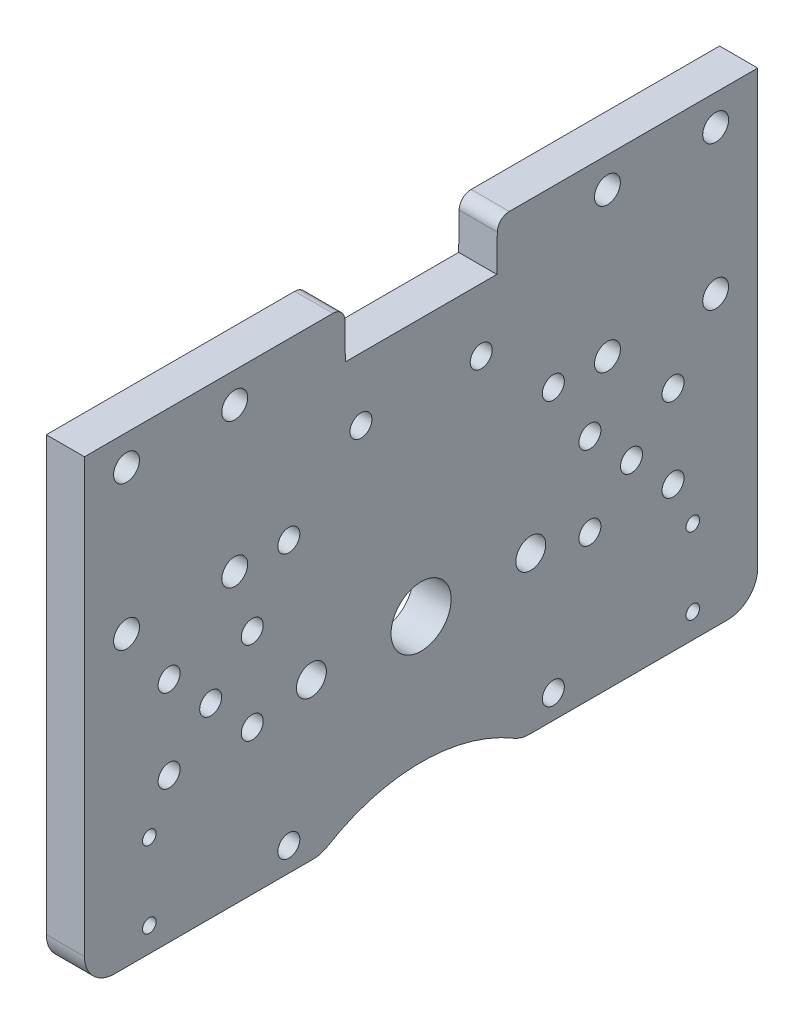
from build123d import *

# Parameters (mm, degrees)
SKETCH1_W                 = 112
SKETCH1_H                 = 77
BOSS_EXTRUDE1_DEPTH       = 6.35
F_6_CLEARANCE_HOLE1_D     = 3.6576
SKETCH5_R                 = 5
CUT_EXTRUDE1_DEPTH        = 7.35
F_6_CLEARANCE_HOLE2_D     = 3.6576
F_10_CLEARANCE_HOLE1_D    = 4.9784
F_8_CLEARANCE_HOLE2_D     = 4.3053
CUT_EXTRUDE2_DEPTH        = 7.35
F_6_CLEARANCE_HOLE3_D     = 3.6576
FILLET2_R                 = 2
SKETCH25_R                = 30
CUT_EXTRUDE3_DEPTH        = 7.35
FILLET1_R                 = 5
TAP_DRILL_FOR_4_40_TAP1_D = 2.2606


with BuildPart() as part:
    # Sketch1 → Boss-Extrude1 (new body)
    with BuildSketch(Plane(origin=(0, 0, 0), x_dir=(0, 0, -1), z_dir=(1, 0, 0))):
        with Locations((0, 12.5)):
            Rectangle(SKETCH1_W, SKETCH1_H)
    extrude(amount=BOSS_EXTRUDE1_DEPTH)

    # #6 Clearance Hole1 (through all)
    with Locations(Plane(origin=(6.35, 0, 0), x_dir=(0, 0, -1), z_dir=(1, 0, 0))):
        with Locations((-22, 22), (22, 22), (22, -22), (-22, -22)):
            Hole(F_6_CLEARANCE_HOLE1_D / 2)

    # Sketch5 → Cut-Extrude1 (cut, through all)
    with BuildSketch(Plane(origin=(6.35, 0, 0), x_dir=(0, 0, -1), z_dir=(1, 0, 0))):
        Circle(SKETCH5_R)
    extrude(amount=-CUT_EXTRUDE1_DEPTH, mode=Mode.SUBTRACT)

    # #6 Clearance Hole2 (through all)
    with Locations(Plane(origin=(6.35, 0, 0), x_dir=(0, 0, -1), z_dir=(1, 0, 0))):
        with Locations((-41.914797213, 11.914797213), (-28.085202787, 11.914797213), (-28.085202787, -1.914797213), (-41.914797213, -1.914797213), (28.085202787, 11.914797213), (28.085202787, -1.914797213), (41.914797213, -1.914797213), (41.914797213, 11.914797213), (-35, 5), (35, 5)):
            Hole(F_6_CLEARANCE_HOLE2_D / 2)

    # #10 Clearance Hole1 (through all)
    with Locations(Plane.ZY):
        with Locations((18.25, 0), (-18.25, 0)):
            Hole(F_10_CLEARANCE_HOLE1_D / 2)

    # #8 Clearance Hole2 (through all)
    with Locations(Plane(origin=(0, 45.97, 49), x_dir=(0, 0, -1), z_dir=(-1, 0, 0))):
        with Locations((0, 0), (18, 0), (18, 24), (0, 24), (80, 0), (80, 24), (98, 24), (98, 0)):
            Hole(F_8_CLEARANCE_HOLE2_D / 2)

    # Sketch22 → Cut-Extrude2 (cut, through all)
    with BuildSketch(Plane.ZY):
        Polygon((12.7, 51), (-12.7, 51), (-12.6, 42.97), (12.6, 42.97), align=None)
    extrude(amount=-CUT_EXTRUDE2_DEPTH, mode=Mode.SUBTRACT)

    # #6 Clearance Hole3 (through all)
    with Locations(Plane(origin=(0, 32.5052, 10), x_dir=(0, 0, -1), z_dir=(-1, 0, 0))):
        with Locations((0, 0), (20, 0)):
            Hole(F_6_CLEARANCE_HOLE3_D / 2)

    # Fillet2
    fillet2_edges = [part.edges().sort_by_distance(p)[0] for p in [
        (3.175, 51, 12.7),
        (3.175, 51, -12.7),
    ]]
    fillet(fillet2_edges, radius=FILLET2_R)

    # Sketch25 → Cut-Extrude3 (cut, through all)
    with BuildSketch(Plane.ZY):
        with Locations((0, -51)):
            Circle(SKETCH25_R)
    extrude(amount=-CUT_EXTRUDE3_DEPTH, mode=Mode.SUBTRACT)

    # Fillet1
    fillet1_edges = [part.edges().sort_by_distance(p)[0] for p in [
        (3.175, -26, -16.583123952),
        (3.175, -26, 16.583123952),
        (3.175, -26, -56),
        (3.175, -26, 56),
    ]]
    fillet(fillet1_edges, radius=FILLET1_R)

    # Tap Drill for #4-40 Tap1 (through all)
    with Locations(Plane(origin=(0, -21.924, 45.205), x_dir=(0, 0, -1), z_dir=(-1, 0, 0))):
        with Locations((0, 0), (0, -12.7)):
            tap_drill_for_4_40_tap1 = Hole(TAP_DRILL_FOR_4_40_TAP1_D / 2)

    # Mirror1: Tap Drill for #4-40 Tap1 across plane
    add(tap_drill_for_4_40_tap1.mirror(Plane.XY), mode=Mode.SUBTRACT)


solid = part.part
